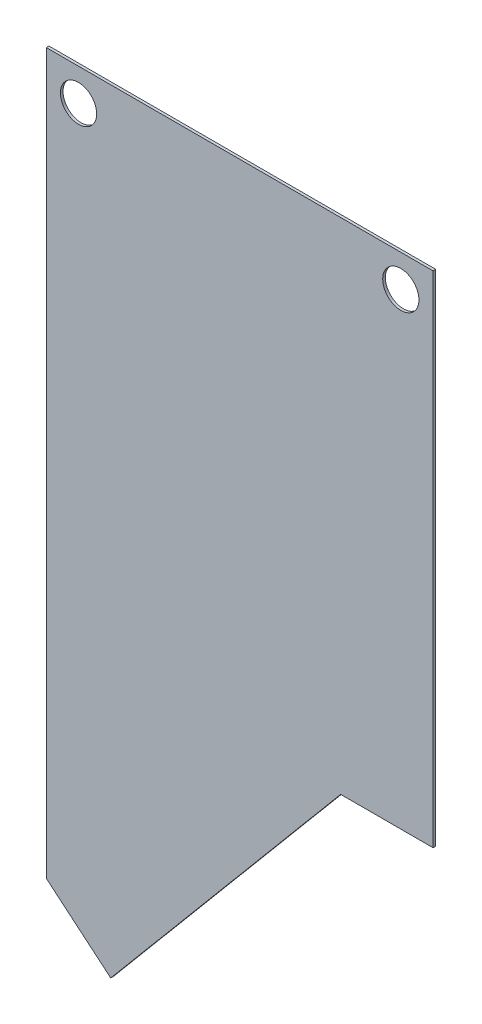
from build123d import *

# Parameters (mm, degrees)
SKETCH1_W           = 304.8
SKETCH1_H           = 635
BOSS_EXTRUDE1_DEPTH = 2.1082
SKETCH3_R           = 14.2875
CUT_EXTRUDE2_DEPTH  = 2.1082
SKETCH4_R           = 14.2875
CUT_EXTRUDE3_DEPTH  = 2.1082
CUT_EXTRUDE4_DEPTH  = 3.1082


with BuildPart() as part:
    # Sketch1 → Boss-Extrude1 (new body)
    with BuildSketch(Plane.XY):
        with Locations((101.6, -317.5)):
            Rectangle(SKETCH1_W, SKETCH1_H)
    extrude(amount=BOSS_EXTRUDE1_DEPTH)

    # Sketch3 → Cut-Extrude2 (cut)
    with BuildSketch(Plane(origin=(0, 0, 0), x_dir=(-1, 0, 0), z_dir=(0, 0, -1))):
        with Locations((25.4, -25.4)):
            Circle(SKETCH3_R)
    extrude(amount=-CUT_EXTRUDE2_DEPTH, mode=Mode.SUBTRACT)

    # Sketch4 → Cut-Extrude3 (cut)
    with BuildSketch(Plane(origin=(0, 0, 0), x_dir=(-1, 0, 0), z_dir=(0, 0, -1))):
        with Locations((-228.6, -25.4)):
            Circle(SKETCH4_R)
    extrude(amount=-CUT_EXTRUDE3_DEPTH, mode=Mode.SUBTRACT)

    # Sketch5 → Cut-Extrude4 (cut, through all)
    with BuildSketch(Plane(origin=(0, 0, 0), x_dir=(-1, 0, 0), z_dir=(0, 0, -1))):
        Polygon((-254, -635), (-254, -393.7), (-181.170170025, -393.7), (0, -609.6), (50.8, -566.973738736), (50.8, -635), align=None)
    extrude(amount=-CUT_EXTRUDE4_DEPTH, mode=Mode.SUBTRACT)


solid = part.part
